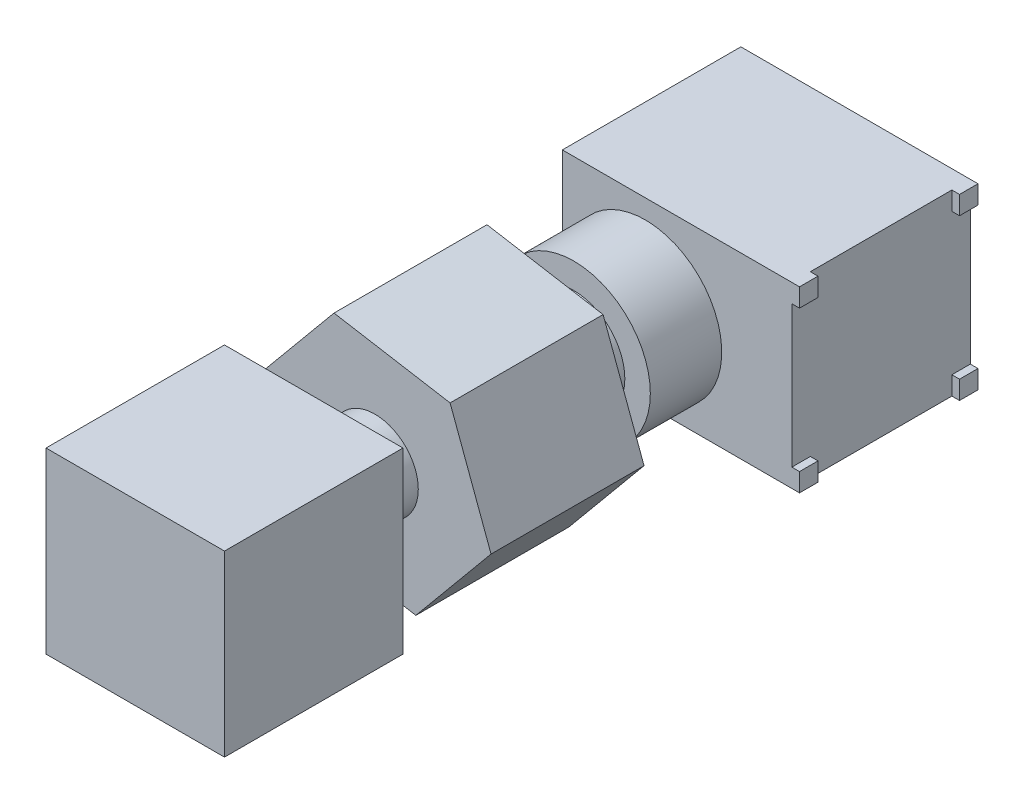
from build123d import *

# Parameters (mm, degrees)
SKETCH1_W           = 9
SKETCH1_H           = 7
BOSS_EXTRUDE1_DEPTH = 7
SKETCH4_W           = 0.725
SKETCH4_H           = 0.725
BOSS_EXTRUDE3_DEPTH = 0.3
SKETCH_1_R          = 3
EXTRUDE_1_DEPTH     = 2.8
SKETCH_2_R          = 2
EXTRUDE_2_DEPTH     = 1.8
EXTRUDE_3_DEPTH     = 6
SKETCH_4_R          = 1.7
EXTRUDE_4_DEPTH     = 2.4
SKETCH_5_W          = 7
SKETCH_5_H          = 7
EXTRUDE_5_DEPTH     = 7


with BuildPart() as part:
    # Sketch1 → Boss-Extrude1 (new body)
    with BuildSketch(Plane(origin=(0, 0, 0), x_dir=(1, 0, 0), z_dir=(0, 1, 0))):
        Rectangle(SKETCH1_W, SKETCH1_H)
    extrude(amount=BOSS_EXTRUDE1_DEPTH)

    # Sketch4 → Boss-Extrude3 (add)
    with BuildSketch(Plane(origin=(4.5, 0, 0), x_dir=(0, 0, -1), z_dir=(1, 0, 0))):
        with Locations((-3.1375, 6.6375)):
            Rectangle(SKETCH4_W, SKETCH4_H)
        with Locations((3.1375, 6.6375)):
            Rectangle(SKETCH4_W, SKETCH4_H)
        with Locations((-3.1375, 0.3625)):
            Rectangle(SKETCH4_W, SKETCH4_H)
        with Locations((3.1375, 0.3625)):
            Rectangle(SKETCH4_W, SKETCH4_H)
    extrude(amount=BOSS_EXTRUDE3_DEPTH)

    # ｽｹｯﾁ1 → ﾎﾞｽ - 押し出し1 (add)
    with BuildSketch(Plane.XY.offset(3.5)):
        with Locations((-1.25, 3.25)):
            Circle(SKETCH_1_R)
    extrude(amount=EXTRUDE_1_DEPTH)

    # ｽｹｯﾁ2 → ﾎﾞｽ - 押し出し2 (add)
    with BuildSketch(Plane.XY.offset(6.3)):
        with Locations((-1.25, 3.25)):
            Circle(SKETCH_2_R)
    extrude(amount=EXTRUDE_2_DEPTH)

    # ｽｹｯﾁ3 → ﾎﾞｽ - 押し出し3 (add)
    with BuildSketch(Plane.XY.offset(8.1)):
        Polygon((1.697866371, 6.805758315), (-2.855443845, 7.580806321), (-5.803310216, 4.025048007), (-4.197866371, -0.305758315), (0.355443845, -1.080806321), (3.303310216, 2.474951993), align=None)
    extrude(amount=EXTRUDE_3_DEPTH)

    # ｽｹｯﾁ4 → ﾎﾞｽ - 押し出し4 (add)
    with BuildSketch(Plane.XY.offset(14.1)):
        with Locations((-1.25, 3.25)):
            Circle(SKETCH_4_R)
    extrude(amount=EXTRUDE_4_DEPTH)

    # ｽｹｯﾁ5 → ﾎﾞｽ - 押し出し5 (add)
    with BuildSketch(Plane.XY.offset(16.5)):
        with Locations((-1.25, 3.25)):
            Rectangle(SKETCH_5_W, SKETCH_5_H)
    extrude(amount=EXTRUDE_5_DEPTH)


solid = part.part
